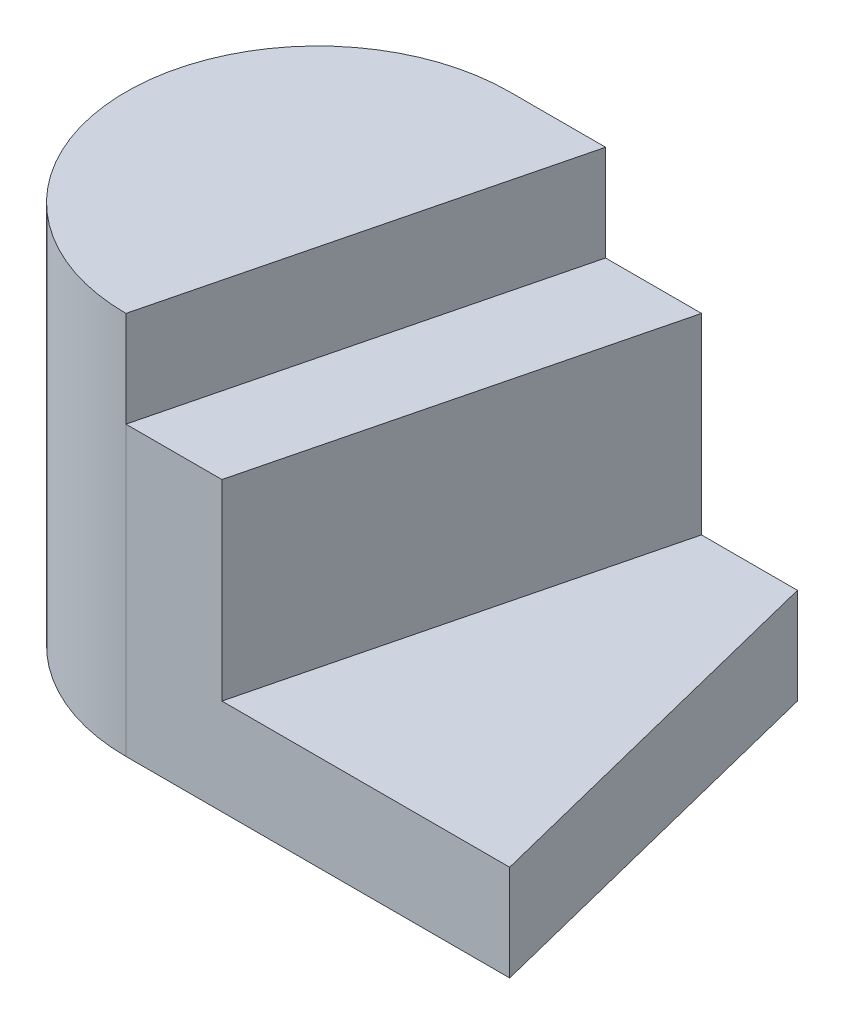
from build123d import *

# Parameters (mm, degrees)
BOSS_EXTRUDE1_DEPTH = 40
BOSS_EXTRUDE2_DEPTH = 30
BOSS_EXTRUDE3_DEPTH = 10


with BuildPart() as part:
    # Sketch1 → Boss-Extrude1 (new body)
    with BuildSketch(Plane(origin=(0, 0, 0), x_dir=(1, 0, 0), z_dir=(0, 1, 0))):
        with BuildLine():
            ThreePointArc((-40, 40), (-60, 20), (-40, 0))
            Line((-40, 0), (-30, 40))
            Line((-30, 40), (-40, 40))
        make_face()
    extrude(amount=BOSS_EXTRUDE1_DEPTH)

    # Sketch1_3 → Boss-Extrude2 (add)
    with BuildSketch(Plane(origin=(0, 0, 0), x_dir=(1, 0, 0), z_dir=(0, 1, 0))):
        Polygon((-40, 0), (-30, 0), (-20, 40), (-30, 40), align=None)
    extrude(amount=BOSS_EXTRUDE2_DEPTH)

    # Sketch1_4 → Boss-Extrude3 (add)
    with BuildSketch(Plane(origin=(0, 0, 0), x_dir=(1, 0, 0), z_dir=(0, 1, 0))):
        Polygon((-30, 0), (0, 0), (-10, 40), (-20, 40), align=None)
    extrude(amount=BOSS_EXTRUDE3_DEPTH)


solid = part.part
